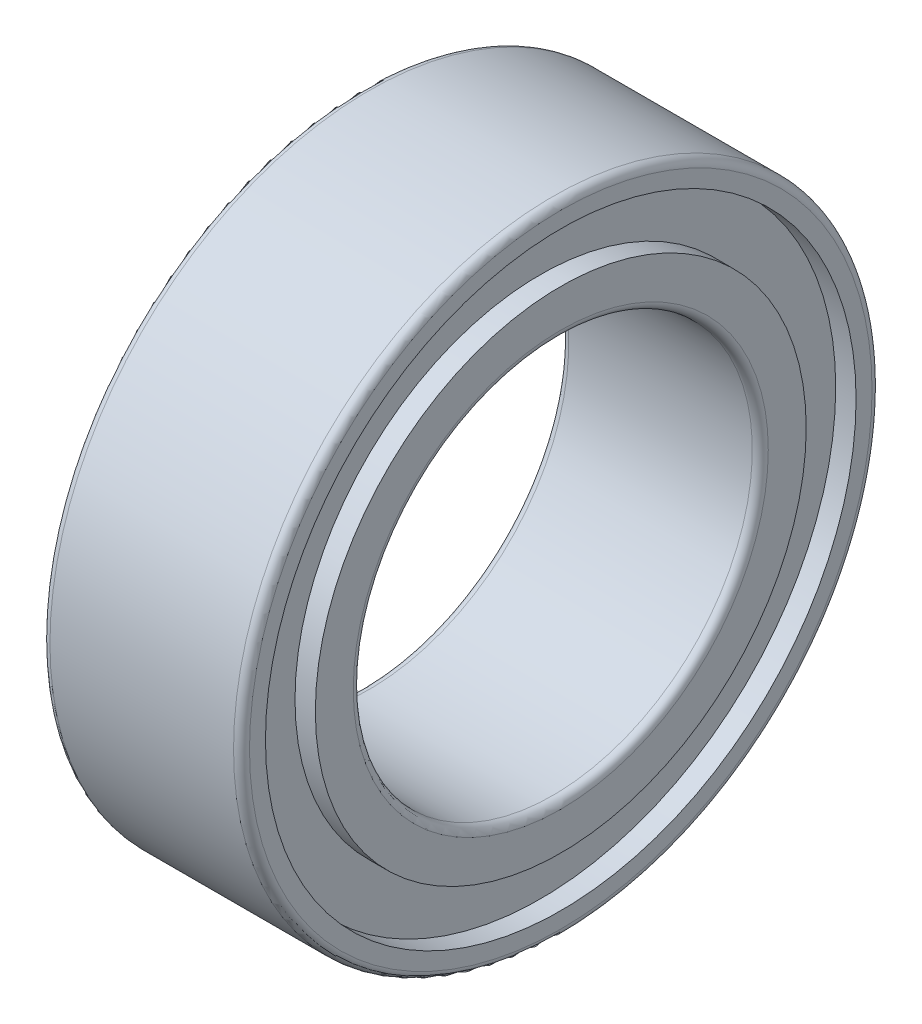
from build123d import *


with BuildPart() as part:
    # Sketch1 → Revolve1 (revolve)
    with BuildSketch(Plane.XY):
        with BuildLine():
            Line((0, 3.9), (0, 3.7))
            Line((0, 3.7), (0.255, 3.7))
            Line((0.255, 3.7), (0.255, 3.075))
            Line((0.255, 3.075), (0, 3.075))
            Line((0, 3.075), (0, 2.6))
            ThreePointArc((0, 2.6), (0.029289322, 2.529289322), (0.1, 2.5))
            Line((0.1, 2.5), (2.4, 2.5))
            ThreePointArc((2.4, 2.5), (2.470710678, 2.529289322), (2.5, 2.6))
            Line((2.5, 2.6), (2.5, 3.075))
            Line((2.5, 3.075), (2.245, 3.075))
            Line((2.245, 3.075), (2.245, 3.7))
            Line((2.245, 3.7), (2.5, 3.7))
            Line((2.5, 3.7), (2.5, 3.9))
            ThreePointArc((2.5, 3.9), (2.470710678, 3.970710678), (2.4, 4))
            Line((2.4, 4), (0.1, 4))
            ThreePointArc((0.1, 4), (0.029289322, 3.970710678), (0, 3.9))
        make_face()
    revolve(axis=Axis((2.4, 0, 0), (-1, 0, 0)))


solid = part.part
